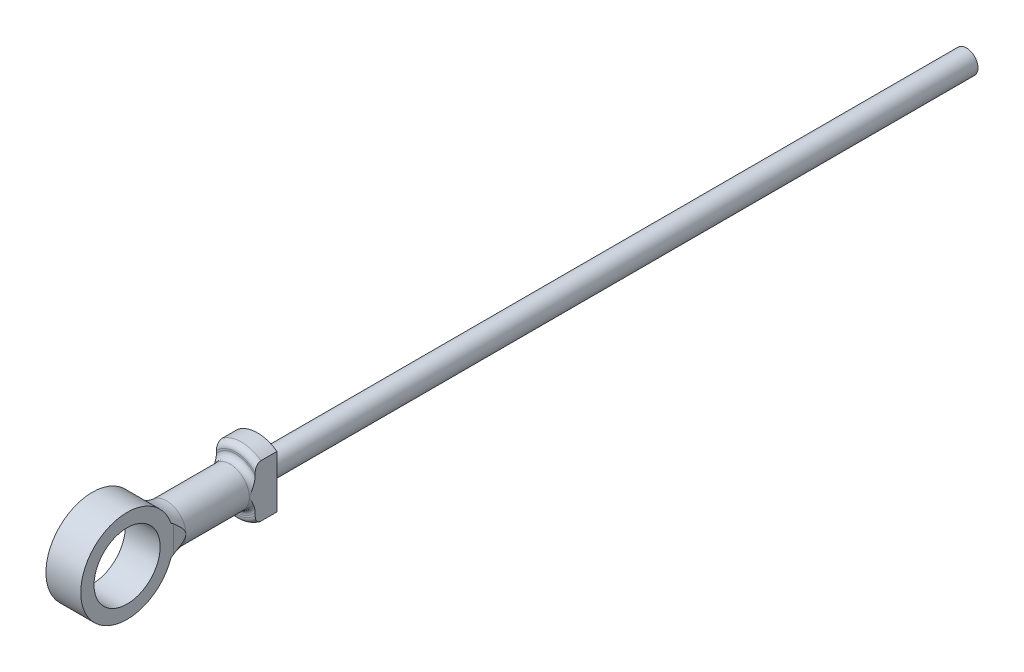
from build123d import *

# Parameters (mm, degrees)
SKETCH1_R                = 2
BOSS_EXTRUDE1_DEPTH      = 156.17
SKETCH2_R                = 5.62
BOSS_EXTRUDE2_DEPTH      = 3.75
SKETCH3_R                = 3.342777959
BOSS_EXTRUDE3_DEPTH      = 14.75
FILLET4_R                = 1
FILLET5_R                = 1
SKETCH4_R                = 8
SKETCH4_R_2              = 5.7
BOSS_EXTRUDE4_DEPTH      = 5
BOSS_EXTRUDE4_DEPTH_BACK = 5
SKETCH7_W                = 5.315591211
SKETCH7_H                = 6.235782502
CUT_EXTRUDE2_DEPTH       = 190.921808488
CUT_EXTRUDE2_DEPTH_BACK  = 190.921808488
SKETCH8_W                = 43.943045651
SKETCH8_H                = 13.288257187
CUT_EXTRUDE3_DEPTH       = 190.868067628
CUT_EXTRUDE3_DEPTH_BACK  = 190.868067628


with BuildPart() as part:
    # Sketch1 → Boss-Extrude1 (new body)
    with BuildSketch(Plane.XY):
        Circle(SKETCH1_R)
    extrude(amount=BOSS_EXTRUDE1_DEPTH)

    # Sketch8 → Cut-Extrude3 (cut, two sides)
    with BuildSketch(Plane(origin=(0, 0, 0), x_dir=(0, 0, -1), z_dir=(1, 0, 0))) as cut_extrude3_sk:
        with Locations((-11.938978735, -2.807349683)):
            Rectangle(SKETCH8_W, SKETCH8_H)
    extrude(amount=CUT_EXTRUDE3_DEPTH, mode=Mode.SUBTRACT)
    extrude(cut_extrude3_sk.sketch, amount=-CUT_EXTRUDE3_DEPTH_BACK, mode=Mode.SUBTRACT)


with BuildPart() as body_2:
    # Sketch2 → Boss-Extrude2 (new body)
    with BuildSketch(Plane.XY.offset(156.17)):
        Circle(SKETCH2_R)
    extrude(amount=BOSS_EXTRUDE2_DEPTH)

    # Sketch3 → Boss-Extrude3 (add)
    with BuildSketch(Plane.XY.offset(159.92)):
        Circle(SKETCH3_R)
    extrude(amount=BOSS_EXTRUDE3_DEPTH)

    # Fillet4
    fillet4_edges = [body_2.edges().sort_by_distance(p)[0] for p in [
        (-3.342777959, 0, 159.92),
    ]]
    fillet(fillet4_edges, radius=FILLET4_R)

    # Fillet5
    fillet5_edges = [body_2.edges().sort_by_distance(p)[0] for p in [
        (-5.62, 0, 159.92),
    ]]
    fillet(fillet5_edges, radius=FILLET5_R)

    # Sketch4 → Boss-Extrude4 (add, two sides)
    with BuildSketch(Plane(origin=(0, 0, 0), x_dir=(0, 0, -1), z_dir=(1, 0, 0))) as boss_extrude4_sk:
        with Locations((-181.67, 0)):
            Circle(SKETCH4_R)
        with Locations((-181.67, 0)):
            Circle(SKETCH4_R_2, mode=Mode.SUBTRACT)
    extrude(amount=BOSS_EXTRUDE4_DEPTH)
    extrude(boss_extrude4_sk.sketch, amount=-BOSS_EXTRUDE4_DEPTH_BACK)


with BuildPart() as body_3:
    # Sketch4_4 → Revolve2 (revolve)
    with BuildSketch(Plane(origin=(0, 0, 0), x_dir=(0, 0, -1), z_dir=(1, 0, 0))):
        with BuildLine():
            Line((-171.86665682, 0), (-173.67, 0))
            ThreePointArc((-173.67, 0), (-174.027795759, -2.365737588), (-175.069178584, -4.519862457))
            add(Edge.make_bspline(
                [(-175.069178584, -4.519862457), (-173.629685325, -3.535053024), (-171.86665682, -3.342777959)],
                knots=[0, 0, 0, 1, 1, 1], degree=2))
            Line((-171.86665682, -3.342777959), (-171.86665682, 0))
        make_face()
    revolve(axis=Axis((0, 0, 189.67), (0, 0, -1)))


with BuildPart() as cut_extrude2_tool:
    # Sketch7 → Cut-Extrude2 (new, two sides)
    with BuildSketch(Plane(origin=(0, 0, 0), x_dir=(1, 0, 0), z_dir=(0, 1, 0))) as cut_extrude2_sk:
        Polygon((3, -173.67), (3.34277796, -171.86665682), (8.65836917, -171.86665682), (8.65836917, -190.916502477), (3, -190.916502477), align=None)
        Polygon((-3, -190.916502477), (-8.65836917, -190.916502477), (-8.65836917, -171.86665682), (-3.34277796, -171.86665682), (-3, -173.67), align=None)
        with Locations((-6.000573564, -157.802108749)):
            Rectangle(SKETCH7_W, SKETCH7_H)
        with Locations((6.000573564, -157.802108749)):
            Rectangle(SKETCH7_W, SKETCH7_H)
    extrude(amount=CUT_EXTRUDE2_DEPTH)
    extrude(cut_extrude2_sk.sketch, amount=-CUT_EXTRUDE2_DEPTH_BACK)


with BuildPart() as body_2_1:
    add(body_2.part)

    # Cut-Extrude2: cut by cut_extrude2_tool
    add(cut_extrude2_tool.part, mode=Mode.SUBTRACT)


with BuildPart() as body_3_1:
    add(body_3.part)

    # Cut-Extrude2: cut by cut_extrude2_tool
    add(cut_extrude2_tool.part, mode=Mode.SUBTRACT)


with BuildPart() as body_2_2:
    add(body_2_1.part)

    # Combine1: union body 3
    add(body_3_1.part)


solid = Compound([part.part, body_2_2.part])
